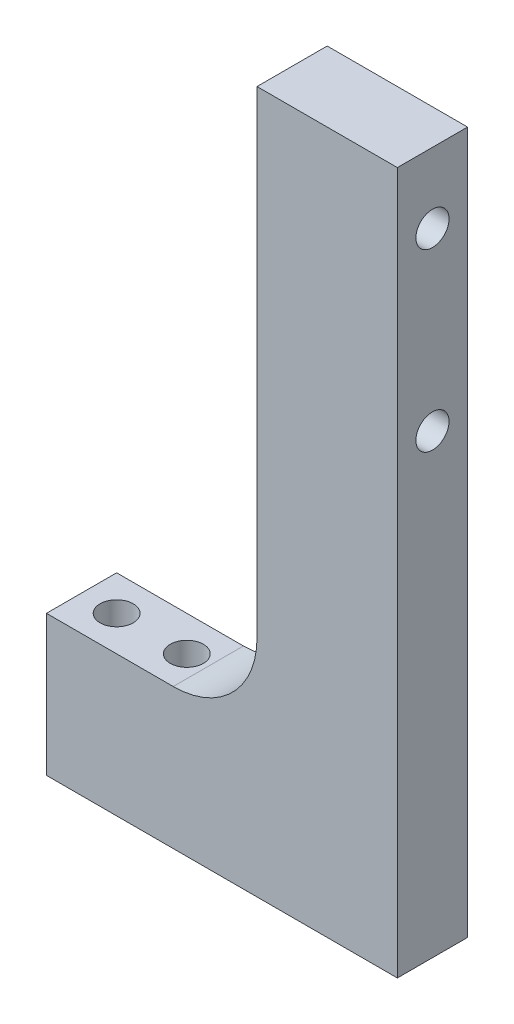
from build123d import *

# Parameters (mm, degrees)
BOSS_EXTRUDE1_DEPTH   = 25.4
M10_CLEARANCE_HOLE1_D = 12
M10_CLEARANCE_HOLE2_D = 12
FILLET1_R             = 30.32


with BuildPart() as part:
    # Sketch1 → Boss-Extrude1 (new body)
    with BuildSketch(Plane.XY):
        Polygon((0, 194.731808123), (0, -59.268191877), (-127, -59.268191877), (-127, -8.468191877), (-50.8, -8.468191877), (-50.8, 194.731808123), align=None)
    extrude(amount=BOSS_EXTRUDE1_DEPTH)

    # M10 Clearance Hole1 (through all)
    with Locations(Plane(origin=(0, -8.468191877, 0), x_dir=(1, 0, 0), z_dir=(0, 1, 0))):
        with Locations((-114.3, -12.7), (-88.9, -12.7)):
            Hole(M10_CLEARANCE_HOLE1_D / 2)

    # M10 Clearance Hole2 (through all)
    with Locations(Plane.ZY.offset(50.8)):
        with Locations((12.7, 169.331808123), (12.7, 105.831808123)):
            Hole(M10_CLEARANCE_HOLE2_D / 2)

    # Fillet1
    fillet1_edges = [part.edges().sort_by_distance(p)[0] for p in [
        (-50.8, -8.468191877, 12.7),
    ]]
    fillet(fillet1_edges, radius=FILLET1_R)


solid = part.part
